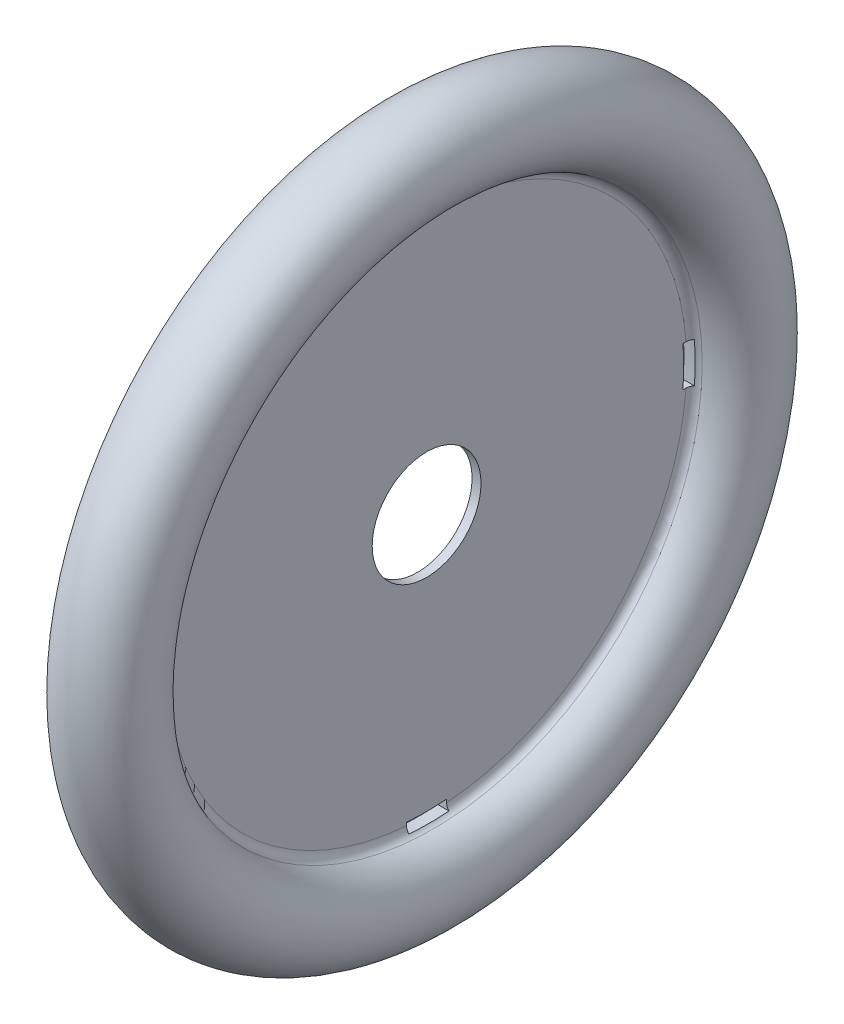
from build123d import *

# Parameters (mm, degrees)
CUT_EXTRUDE1_START = -4.175000103
CUT_EXTRUDE1_DEPTH = 8.731000203
CIRPATTERN1_COUNT  = 4


with BuildPart() as part:
    # Sketch1 → Revolve1 (revolve)
    with BuildSketch(Plane.XY):
        with BuildLine():
            Line((0.4064, 23.088264985), (0.4064, 4.826))
            Line((0.4064, 4.826), (-0.38735, 4.826))
            Line((-0.38735, 4.826), (-0.38735, 23.749))
            ThreePointArc((-0.38735, 23.749), (-0.18294644, 24.280704651), (0.324989744, 24.538564078))
            ThreePointArc((0.324989744, 24.538564078), (2.869300627, 29.034920751), (-2.213992628, 29.957347378))
            Line((-2.213992628, 29.957347378), (-2.7686, 30.525193947))
            ThreePointArc((-2.7686, 30.525193947), (3.44971773, 29.639878479), (0.999857944, 23.856328886))
            ThreePointArc((0.999857944, 23.856328886), (0.572049338, 23.573577896), (0.4064, 23.088264985))
        make_face()
    revolve(axis=Axis((0, 0, 0), (1, 0, 0)))

    # Sketch2 → Cut-Extrude1 (cut)
    with BuildSketch(Plane(origin=(0.4064, 0, 0), x_dir=(0, 0, -1), z_dir=(1, 0, 0)).offset(CUT_EXTRUDE1_START)):
        with BuildLine():
            Line((-1.778, 22.742190979), (-1.778, 23.554990979))
            ThreePointArc((-1.778, 23.554990979), (0, 23.622), (1.778, 23.554990979))
            Line((1.778, 23.554990979), (1.778, 22.742190979))
            ThreePointArc((1.778, 22.742190979), (0, 22.811587724), (-1.778, 22.742190979))
        make_face()
    cut_extrude1 = extrude(amount=CUT_EXTRUDE1_DEPTH, mode=Mode.SUBTRACT)

    # CirPattern1: Cut-Extrude1 ×4 about axis
    cirpattern1_axis = Axis((0, 0, 0), (1, 0, 0))
    for i in range(1, CIRPATTERN1_COUNT):
        add(cut_extrude1.rotate(cirpattern1_axis, i * 360 / CIRPATTERN1_COUNT), mode=Mode.SUBTRACT)


solid = part.part
